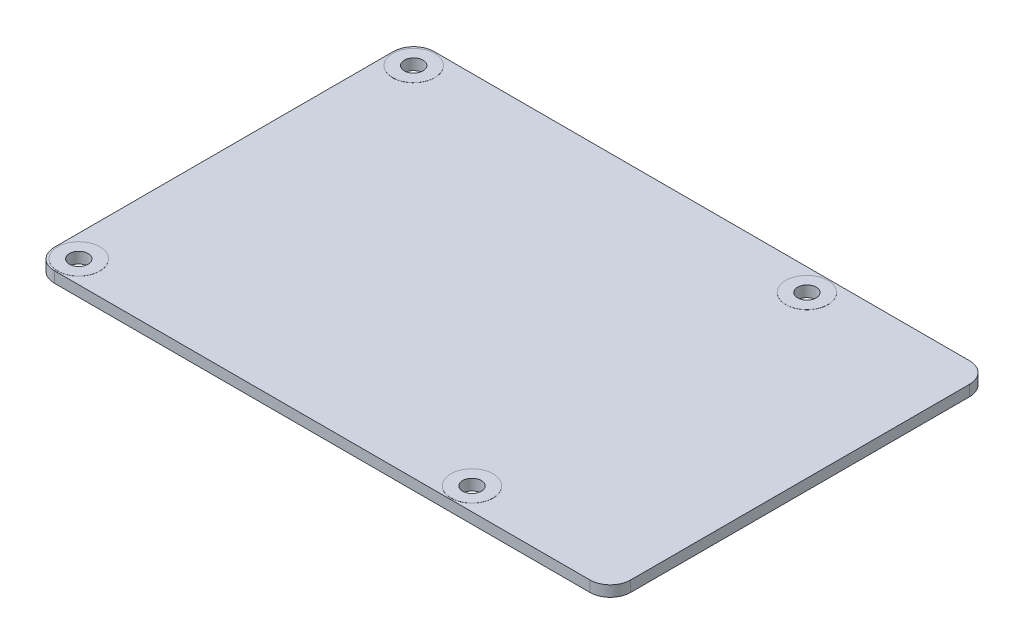
from build123d import *

# Parameters (mm, degrees)
SKETCH2_R           = 3.1
BOSS_EXTRUDE1_DEPTH = 0.8
SKETCH3_R           = 3.1
SKETCH3_R_2         = 1.375
BOSS_EXTRUDE3_DEPTH = 0.815


with BuildPart() as part:
    # Sketch2 → Boss-Extrude1 (new body, symmetric)
    with BuildSketch(Plane(origin=(0, 0, 0), x_dir=(1, 0, 0), z_dir=(0, 1, 0))):
        with BuildLine():
            Line((3, 56), (82, 56))
            ThreePointArc((82, 56), (84.121320344, 55.121320344), (85, 53))
            Line((85, 53), (85, 3))
            ThreePointArc((85, 3), (84.121320344, 0.878679656), (82, 0))
            Line((82, 0), (3, 0))
            ThreePointArc((3, 0), (0.878679656, 0.878679656), (0, 3))
            Line((0, 3), (0, 53))
            ThreePointArc((0, 53), (0.878679656, 55.121320344), (3, 56))
        make_face()
        with Locations((3.3, 52.7)):
            Circle(SKETCH2_R, mode=Mode.SUBTRACT)
        with Locations((3.3, 3.3)):
            Circle(SKETCH2_R, mode=Mode.SUBTRACT)
        with Locations((61.3, 3.3)):
            Circle(SKETCH2_R, mode=Mode.SUBTRACT)
        with Locations((61.3, 52.7)):
            Circle(SKETCH2_R, mode=Mode.SUBTRACT)
    extrude(amount=BOSS_EXTRUDE1_DEPTH, both=True)

    # Sketch3 → Boss-Extrude3 (add, symmetric)
    with BuildSketch(Plane(origin=(0, 0, 0), x_dir=(1, 0, 0), z_dir=(0, 1, 0))):
        with Locations((3.3, 3.3)):
            Circle(SKETCH3_R)
        with Locations((3.3, 3.3)):
            Circle(SKETCH3_R_2, mode=Mode.SUBTRACT)
        with Locations((61.3, 3.3)):
            Circle(SKETCH3_R)
        with Locations((61.3, 3.3)):
            Circle(SKETCH3_R_2, mode=Mode.SUBTRACT)
        with Locations((61.3, 52.7)):
            Circle(SKETCH3_R)
        with Locations((61.3, 52.7)):
            Circle(SKETCH3_R_2, mode=Mode.SUBTRACT)
        with Locations((3.3, 52.7)):
            Circle(SKETCH3_R)
        with Locations((3.3, 52.7)):
            Circle(SKETCH3_R_2, mode=Mode.SUBTRACT)
    extrude(amount=BOSS_EXTRUDE3_DEPTH, both=True)


solid = part.part
